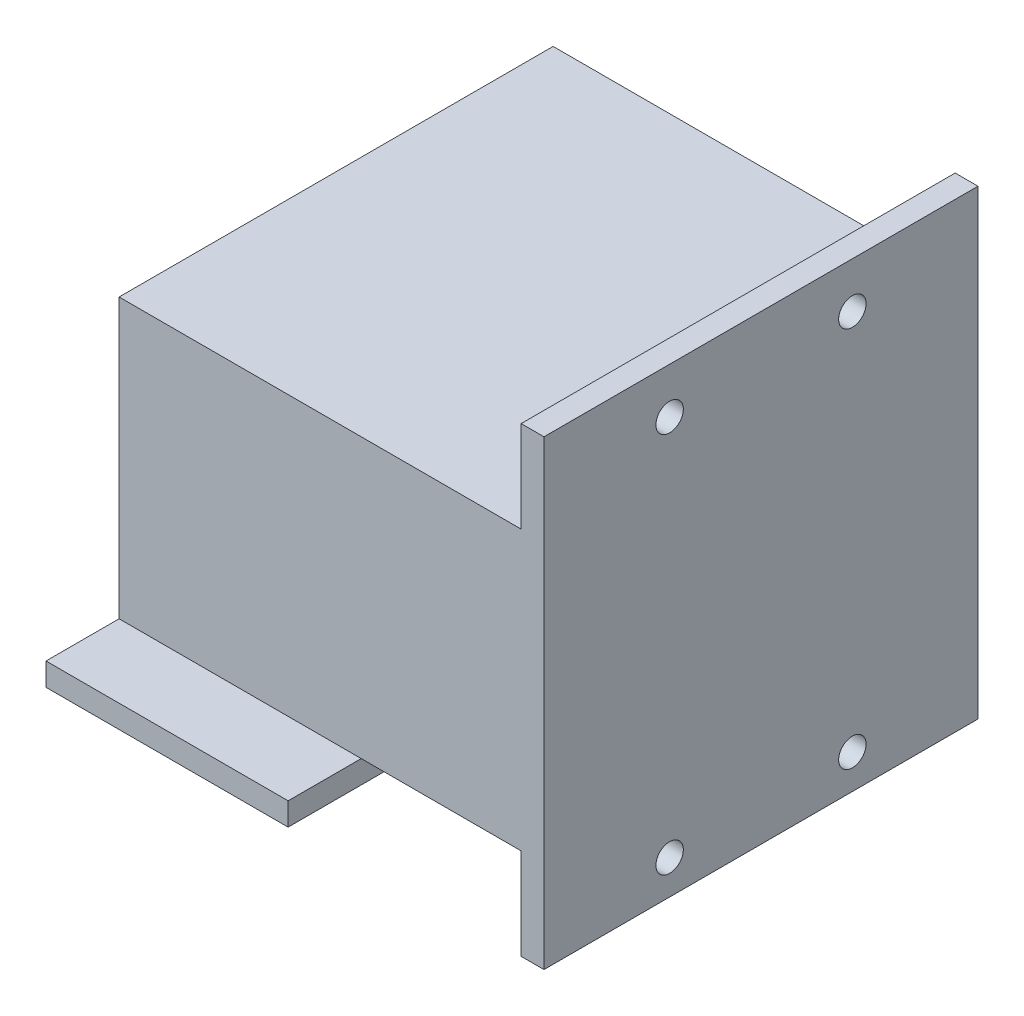
from build123d import *

# Parameters (mm, degrees)
SKETCH1_W           = 26.5
SKETCH1_H           = 47.5
SKETCH1_W_2         = 21.5
SKETCH1_H_2         = 42.5
BOSS_EXTRUDE1_DEPTH = 33
SKETCH2_W           = 21.5
SKETCH2_H           = 42.5
BOSS_EXTRUDE2_DEPTH = 2.5
CUT_EXTRUDE2_DEPTH  = 2.5
SKETCH4_W           = 9.75
SKETCH4_H           = 8
SKETCH4_W_2         = 26.5
BOSS_EXTRUDE3_DEPTH = 2.5
SKETCH7_W           = 47.5
SKETCH7_H           = 30.5
BOSS_EXTRUDE5_DEPTH = 20
SKETCH8_W           = 47.5
SKETCH8_H           = 10
BOSS_EXTRUDE6_DEPTH = 2.5
SKETCH9_R           = 1.5
CUT_EXTRUDE3_DEPTH  = 21.5


with BuildPart() as part:
    # Sketch1 → Boss-Extrude1 (new body)
    with BuildSketch(Plane(origin=(0, 0, 0), x_dir=(1, 0, 0), z_dir=(0, 1, 0))):
        with Locations((0.956397274, -2.454043299)):
            Rectangle(SKETCH1_W, SKETCH1_H)
        with Locations((0.956397274, -2.454043299)):
            Rectangle(SKETCH1_W_2, SKETCH1_H_2, mode=Mode.SUBTRACT)
    extrude(amount=BOSS_EXTRUDE1_DEPTH)

    # Sketch2 → Boss-Extrude2 (add)
    with BuildSketch(Plane(origin=(0, 33, 0), x_dir=(1, 0, 0), z_dir=(0, 1, 0))):
        with Locations((0.956397274, -2.454043299)):
            Rectangle(SKETCH2_W, SKETCH2_H)
    extrude(amount=-BOSS_EXTRUDE2_DEPTH)

    # Sketch3 → Cut-Extrude2 (cut)
    with BuildSketch(Plane(origin=(0, 0, -21.295956701), x_dir=(-1, 0, 0), z_dir=(0, 0, -1))):
        Polygon((2.543602726, 30.5), (2.543602726, 0), (-0.956397274, 0), (-4.456397274, 0), (-4.456397274, 30.5), align=None)
    extrude(amount=-CUT_EXTRUDE2_DEPTH, mode=Mode.SUBTRACT)

    # Sketch4 → Boss-Extrude3 (add)
    with BuildSketch(Plane.XZ):
        with Locations((-7.418602726, -25.295956701)):
            Rectangle(SKETCH4_W, SKETCH4_H)
        with Locations((0.956397274, 30.204043299)):
            Rectangle(SKETCH4_W_2, SKETCH4_H)
        with Locations((9.331397274, -25.295956701)):
            Rectangle(SKETCH4_W, SKETCH4_H)
    extrude(amount=-BOSS_EXTRUDE3_DEPTH)

    # Sketch7 → Boss-Extrude5 (add)
    with BuildSketch(Plane(origin=(14.206397274, 0, 0), x_dir=(0, 0, -1), z_dir=(1, 0, 0))):
        with Locations((-2.454043299, 17.75)):
            Rectangle(SKETCH7_W, SKETCH7_H)
    extrude(amount=BOSS_EXTRUDE5_DEPTH)

    # Sketch8 → Boss-Extrude6 (add)
    with BuildSketch(Plane(origin=(34.206397274, 0, 0), x_dir=(0, 0, -1), z_dir=(1, 0, 0))):
        with Locations((-2.454043299, 38)):
            Rectangle(SKETCH8_W, SKETCH8_H)
        with Locations((-2.454043299, -2.5)):
            Rectangle(SKETCH8_W, SKETCH8_H)
    extrude(amount=-BOSS_EXTRUDE6_DEPTH)

    # Sketch9 → Cut-Extrude3 (cut)
    with BuildSketch(Plane.ZY.offset(-31.706397274)):
        with Locations((-7.545956701, -3.75)):
            Circle(SKETCH9_R)
        with Locations((12.454043299, -3.75)):
            Circle(SKETCH9_R)
        with Locations((-7.545956701, 38)):
            Circle(SKETCH9_R)
        with Locations((12.454043299, 38)):
            Circle(SKETCH9_R)
    extrude(amount=-CUT_EXTRUDE3_DEPTH, mode=Mode.SUBTRACT)


solid = part.part
